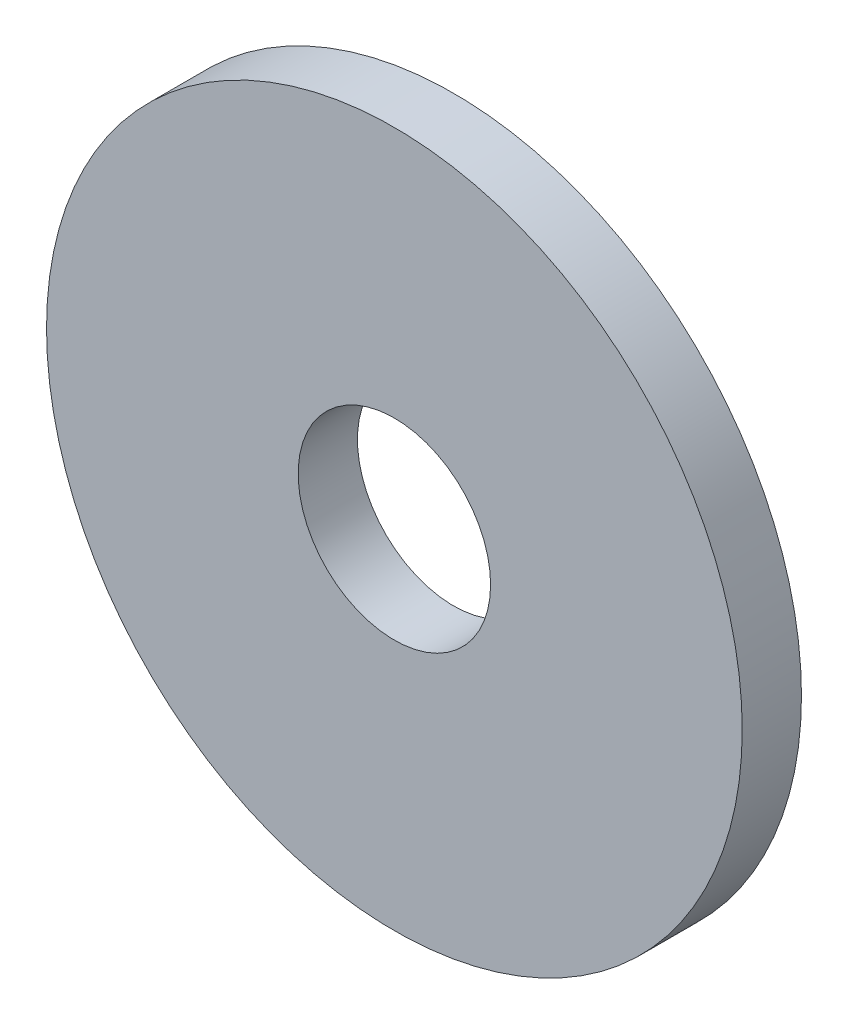
from build123d import *

# Parameters (mm, degrees)
SKETCH3_R           = 9.3218
SKETCH3_R_2         = 2.5781
BOSS_EXTRUDE1_DEPTH = 0.79375


with BuildPart() as part:
    # Sketch3 → Boss-Extrude1 (new body, symmetric)
    with BuildSketch(Plane.XY):
        Circle(SKETCH3_R)
        Circle(SKETCH3_R_2, mode=Mode.SUBTRACT)
    extrude(amount=BOSS_EXTRUDE1_DEPTH, both=True)


solid = part.part
